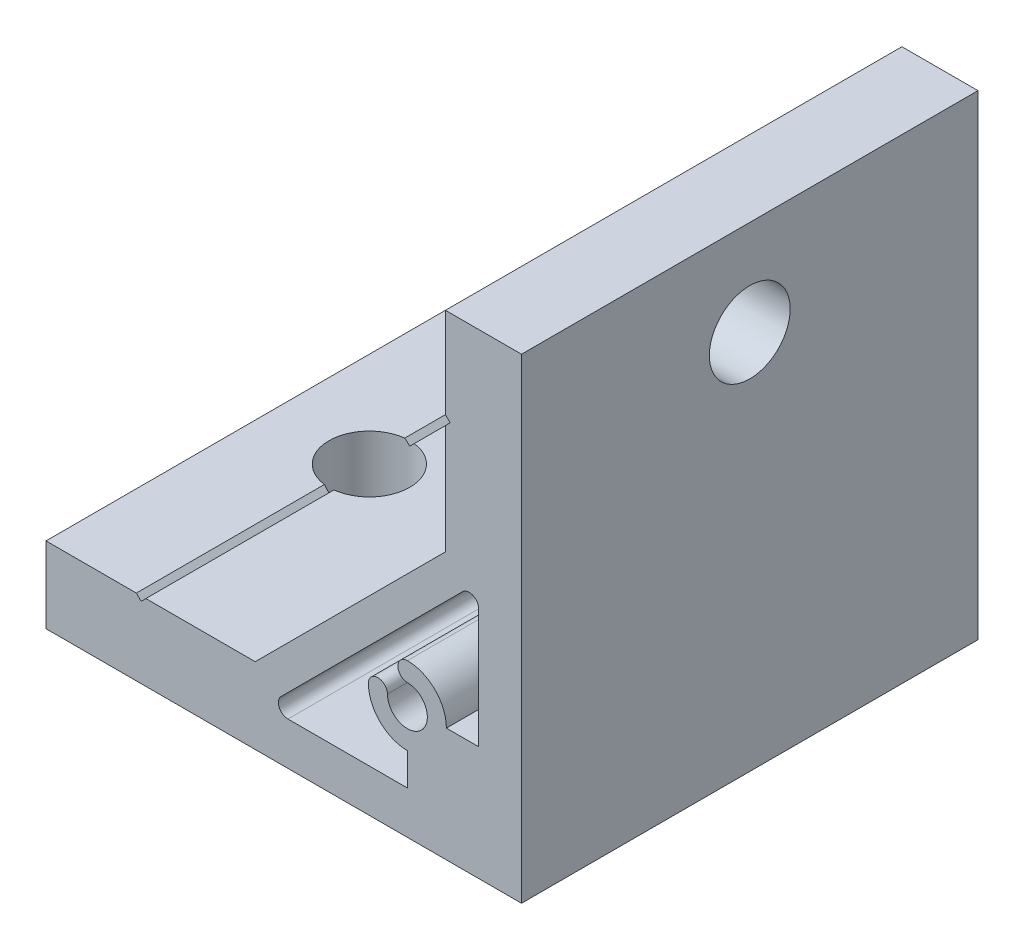
from build123d import *

# Parameters (mm, degrees)
EXTRUDE_1_DEPTH     = 24
SKETCH_2_R          = 4.25
CUT_EXTRUDE_1_DEPTH = 9
SKETCH_3_R          = 4.25
CUT_EXTRUDE_2_DEPTH = 9


with BuildPart() as part:
    # Эскиз1 → Бобышка-Вытянуть1 (new body, symmetric)
    with BuildSketch(Plane.XY):
        Polygon((-50, 0), (0, 0), (0, 50), (-8, 50), (-8, 40.5), (-7.5, 40), (-8, 39.5), (-8, 28), (-28, 8), (-39.5, 8), (-40, 7.5), (-40.5, 8), (-50, 8), align=None)
        with BuildLine():
            Line((-4.5, 12), (-4.5, 24.560303038))
            ThreePointArc((-4.5, 24.560303038), (-5.117316568, 25.484182571), (-6.207106781, 25.267409819))
            Line((-6.207106781, 25.267409819), (-25.267409819, 6.207106781))
            ThreePointArc((-25.267409819, 6.207106781), (-25.484182571, 5.117316568), (-24.560303038, 4.5))
            Line((-24.560303038, 4.5), (-12, 4.5))
            Line((-12, 4.5), (-12, 7.9))
            ThreePointArc((-12, 7.9), (-14.899137803, 9.100862197), (-16.1, 12))
            ThreePointArc((-16.1, 12), (-15.1, 13), (-14.1, 12))
            ThreePointArc((-14.1, 12), (-10.51507576, 10.51507576), (-12, 14.1))
            ThreePointArc((-12, 14.1), (-13, 15.1), (-12, 16.1))
            ThreePointArc((-12, 16.1), (-9.100862197, 14.899137803), (-7.9, 12))
            Line((-7.9, 12), (-4.5, 12))
        make_face(mode=Mode.SUBTRACT)
    extrude(amount=EXTRUDE_1_DEPTH, both=True)

    # Эскиз2 → Вырез-Вытянуть1 (cut, through all)
    with BuildSketch(Plane.ZY.offset(8)):
        with Locations(Location((0, 40, 0), (0, 0, 270))):  # turned: the seam where the file's is
            Circle(SKETCH_2_R)
    extrude(amount=-CUT_EXTRUDE_1_DEPTH, mode=Mode.SUBTRACT)

    # Эскиз3 → Вырез-Вытянуть2 (cut, through all)
    with BuildSketch(Plane(origin=(0, 8, 0), x_dir=(1, 0, 0), z_dir=(0, 1, 0))):
        with Locations(Location((-40, 0, 0), (0, 0, 180))):  # turned: the seam where the file's is
            Circle(SKETCH_3_R)
    extrude(amount=-CUT_EXTRUDE_2_DEPTH, mode=Mode.SUBTRACT)


solid = part.part
